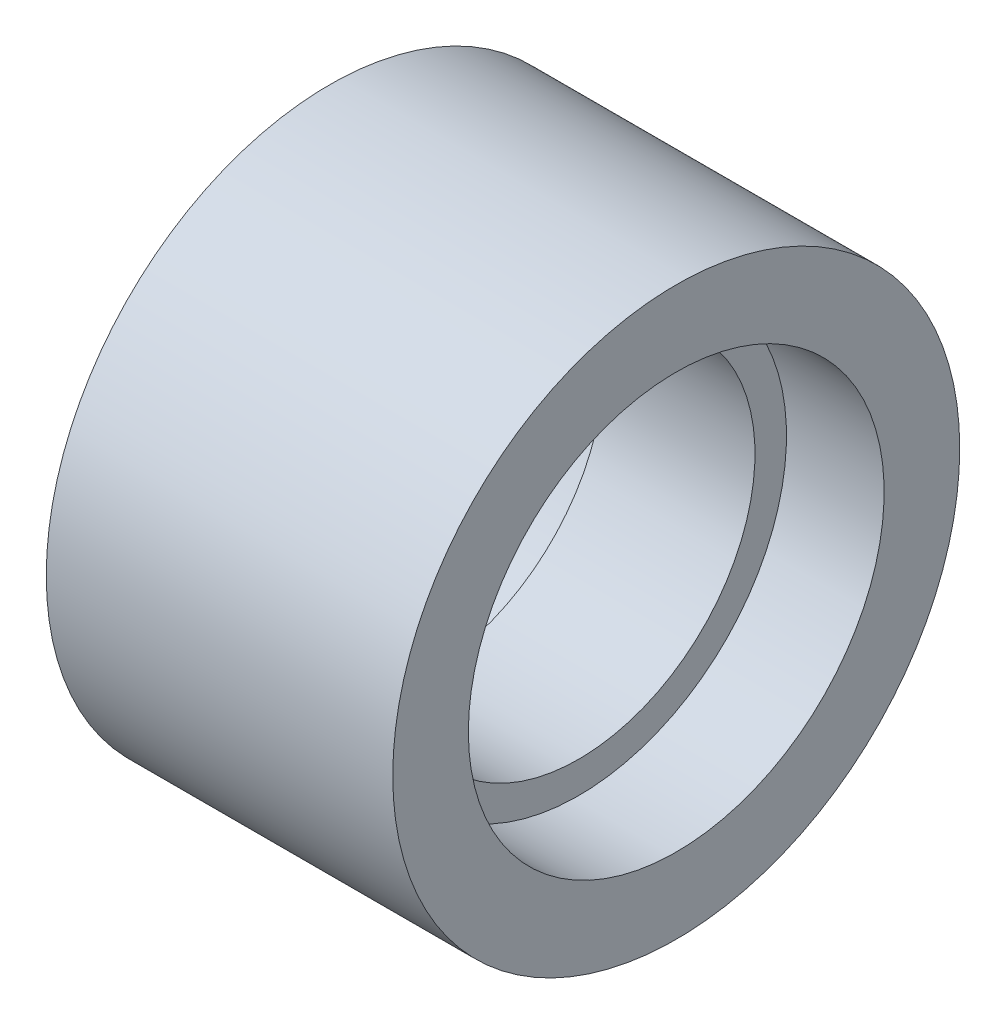
from build123d import *

# Parameters (mm, degrees)
SKETCH1_W   = 110
SKETCH1_H   = 24
SKETCH1_W_2 = 48
SKETCH1_H_2 = 10


with BuildPart() as part:
    # Sketch1 → Revolve1 (revolve)
    with BuildSketch(Plane.XY):
        with Locations((0, 78)):
            Rectangle(SKETCH1_W, SKETCH1_H)
        with Locations((0, 61)):
            Rectangle(SKETCH1_W_2, SKETCH1_H_2)
    revolve(axis=Axis((-9.444444444, 0, 0), (1, 0, 0)))


solid = part.part
